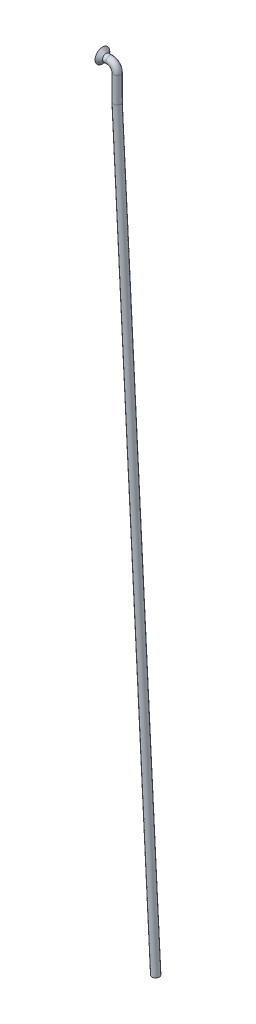
from build123d import *

# Parameters (mm, degrees)
ESQUISSE2_R = 1


with BuildPart() as part:
    # Balayage1: sweep along a path in Esquisse1
    with BuildLine(Plane.XY) as balayage1_path:
        Line((-4, 0), (-2, 0))
        ThreePointArc((-2, 0), (-0.585786438, -0.585786438), (0, -2))
        Line((0, -2), (0, -9))
        Line((0, -9), (10.52014508, -209.736326247))
    # Esquisse2 → Balayage1 (sweep)
    with BuildSketch(Plane(origin=(-4, 0, 0), x_dir=(0, 0, -1), z_dir=(1, 0, 0))):
        Circle(ESQUISSE2_R)
    sweep(path=balayage1_path.line, transition=Transition.RIGHT)

    # Esquisse3 → Révolution1 (revolve)
    with BuildSketch(Plane.XY):
        Polygon((-4, 1), (-4, 2), (-3, 1), align=None)
    revolve(axis=Axis((0, 0, 0), (-1, 0, 0)))


solid = part.part
